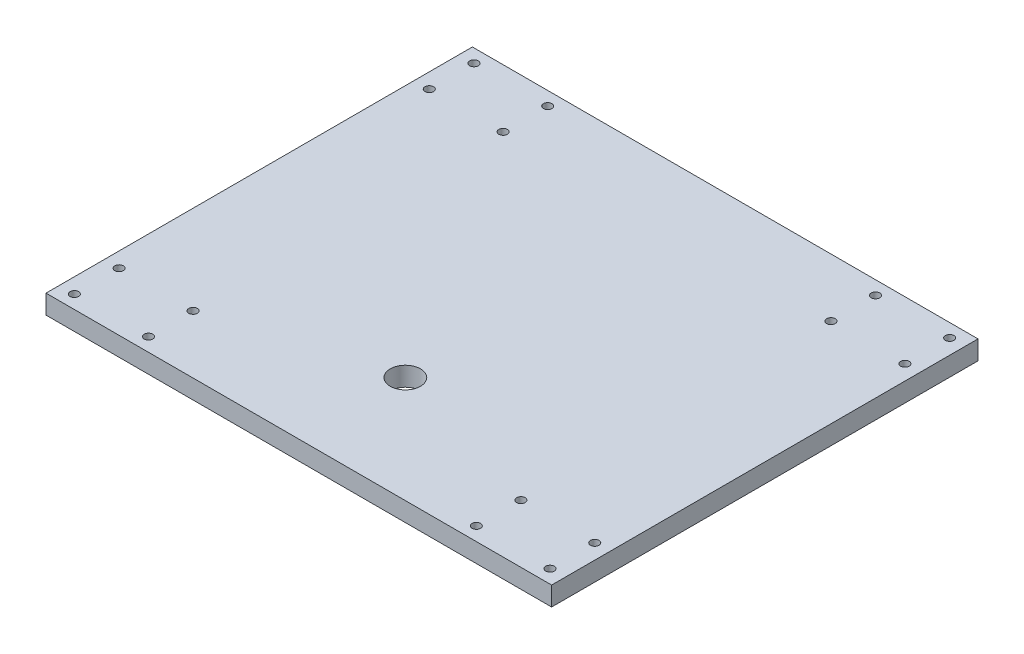
from build123d import *

# Parameters (mm, degrees)
SKETCH1_W           = 504
SKETCH1_H           = 425
SKETCH1_R           = 15.08125
BOSS_EXTRUDE1_DEPTH = 19
SKETCH2_R           = 4.25
CUT_EXTRUDE3_DEPTH  = 19


with BuildPart() as part:
    # Sketch1 → Boss-Extrude1 (new body)
    with BuildSketch(Plane(origin=(0, 0, 0), x_dir=(1, 0, 0), z_dir=(0, 1, 0))):
        with Locations((-252, 212.5)):
            Rectangle(SKETCH1_W, SKETCH1_H)
        with Locations(Location((-252, 106.2, 0), (0, 0, 270))):  # turned: the seam where the file's is
            Circle(SKETCH1_R, mode=Mode.SUBTRACT)
    extrude(amount=BOSS_EXTRUDE1_DEPTH)

    # Sketch2 → Cut-Extrude3 (cut)
    with BuildSketch(Plane(origin=(0, 19, 0), x_dir=(1, 0, 0), z_dir=(0, 1, 0))):
        with Locations(Location((-88.599351486, 57.982002922, 0), (0, 0, 270))):  # turned: the seam where the file's is
            Circle(SKETCH2_R)
        with Locations(Location((-14.939385216, 57.911511452, 0), (0, 0, 270))):  # turned: the seam where the file's is
            Circle(SKETCH2_R)
        with Locations(Location((-88.599351486, 13.532002922, 0), (0, 0, 270))):  # turned: the seam where the file's is
            Circle(SKETCH2_R)
        with Locations(Location((-14.939609501, 13.337039706, 0), (0, 0, 270))):  # turned: the seam where the file's is
            Circle(SKETCH2_R)
        with Locations(Location((-14.939609501, 411.662960294, 0), (0, 0, 90))):  # turned: the seam where the file's is
            Circle(SKETCH2_R)
        with Locations(Location((-88.599351486, 411.467997078, 0), (0, 0, 90))):  # turned: the seam where the file's is
            Circle(SKETCH2_R)
        with Locations(Location((-14.939385216, 367.088488548, 0), (0, 0, 90))):  # turned: the seam where the file's is
            Circle(SKETCH2_R)
        with Locations(Location((-88.599351486, 367.017997078, 0), (0, 0, 90))):  # turned: the seam where the file's is
            Circle(SKETCH2_R)
        with Locations(Location((-415.400648514, 367.017997078, 0), (0, 0, 270))):  # turned: the seam where the file's is
            Circle(SKETCH2_R)
        with Locations(Location((-489.060614784, 367.088488548, 0), (0, 0, 270))):  # turned: the seam where the file's is
            Circle(SKETCH2_R)
        with Locations(Location((-415.400648514, 411.467997078, 0), (0, 0, 270))):  # turned: the seam where the file's is
            Circle(SKETCH2_R)
        with Locations(Location((-489.060390499, 411.662960294, 0), (0, 0, 270))):  # turned: the seam where the file's is
            Circle(SKETCH2_R)
        with Locations(Location((-489.060390499, 13.337039706, 0), (0, 0, 90))):  # turned: the seam where the file's is
            Circle(SKETCH2_R)
        with Locations(Location((-415.400648514, 13.532002922, 0), (0, 0, 90))):  # turned: the seam where the file's is
            Circle(SKETCH2_R)
        with Locations(Location((-489.060614784, 57.911511452, 0), (0, 0, 90))):  # turned: the seam where the file's is
            Circle(SKETCH2_R)
        with Locations(Location((-415.400648514, 57.982002922, 0), (0, 0, 90))):  # turned: the seam where the file's is
            Circle(SKETCH2_R)
    extrude(amount=-CUT_EXTRUDE3_DEPTH, mode=Mode.SUBTRACT)


solid = part.part
